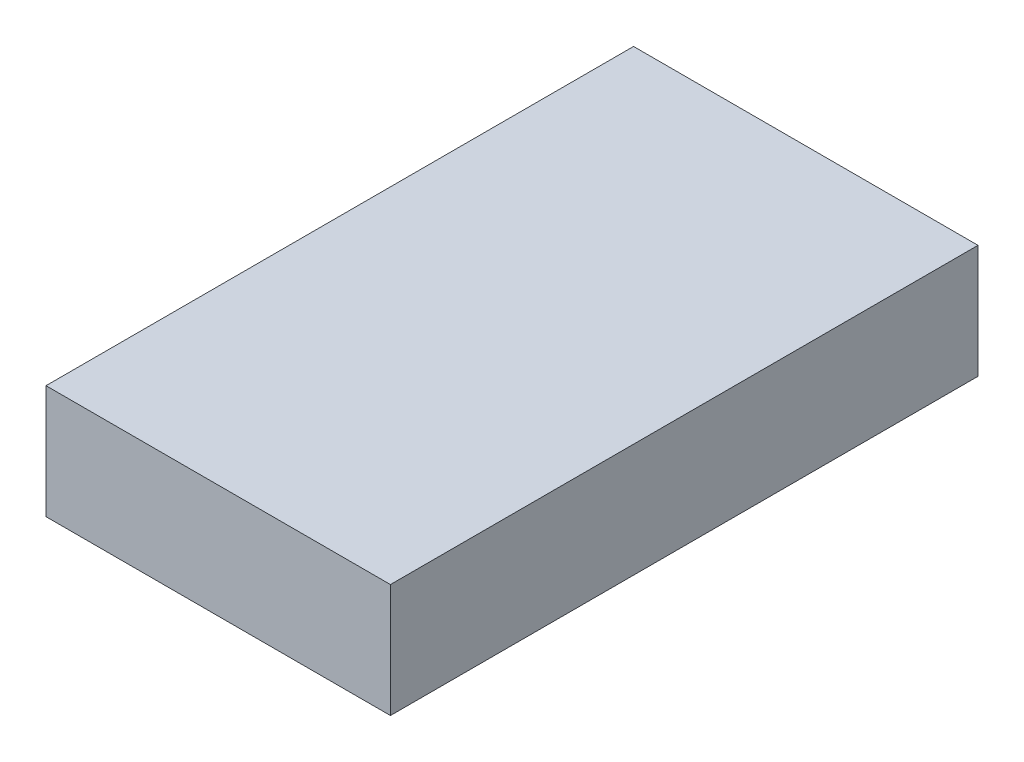
from build123d import *

# Parameters (mm, degrees)
SKETCH1_W           = 85
SKETCH1_H           = 145
BOSS_EXTRUDE1_DEPTH = 28


with BuildPart() as part:
    # Sketch1 → Boss-Extrude1 (new body)
    with BuildSketch(Plane(origin=(0, 0, 0), x_dir=(1, 0, 0), z_dir=(0, 1, 0))):
        Rectangle(SKETCH1_W, SKETCH1_H)
    extrude(amount=BOSS_EXTRUDE1_DEPTH)


solid = part.part
